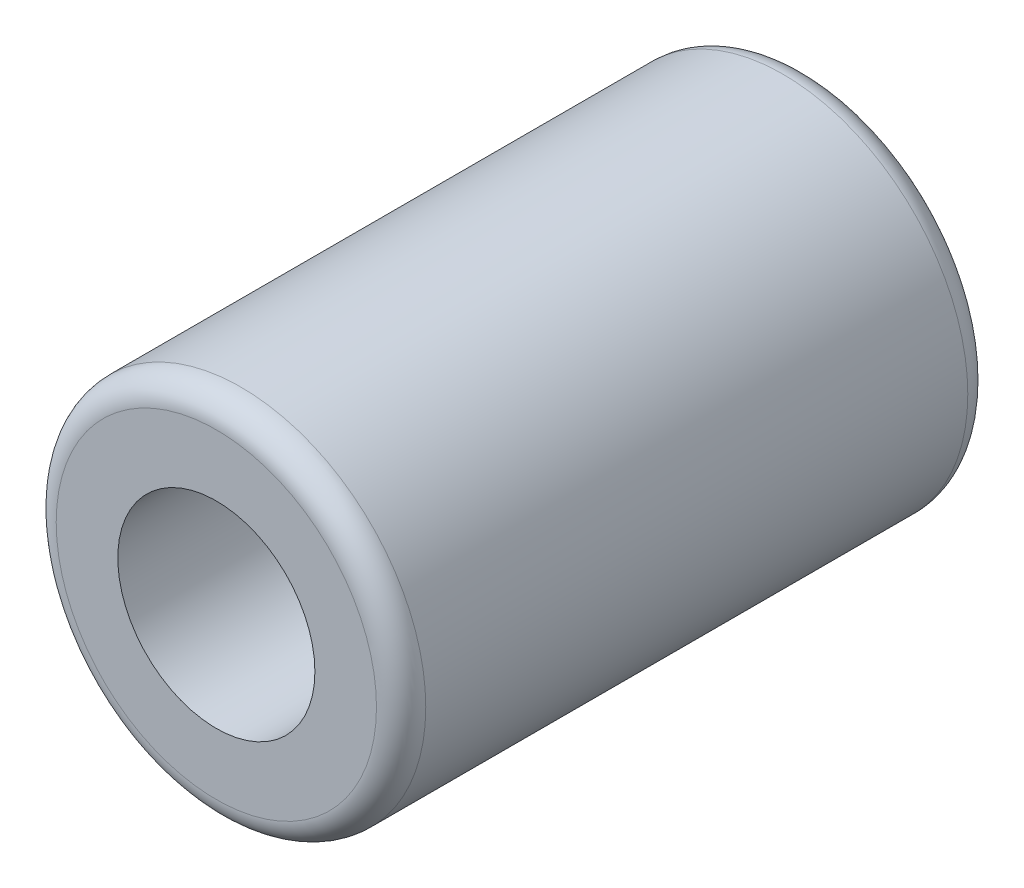
from build123d import *

# Parameters (mm, degrees)
SKETCH1_R           = 7.5
SKETCH1_R_2         = 4
BOSS_EXTRUDE1_DEPTH = 24
FILLET2_R           = 1


with BuildPart() as part:
    # Sketch1 → Boss-Extrude1 (new body)
    with BuildSketch(Plane.XY):
        Circle(SKETCH1_R)
        Circle(SKETCH1_R_2, mode=Mode.SUBTRACT)
    extrude(amount=BOSS_EXTRUDE1_DEPTH)

    # Fillet2
    fillet2_edges = [part.edges().sort_by_distance(p)[0] for p in [
        (-7.5, 0, 0),
        (-7.5, 0, 24),
    ]]
    fillet(fillet2_edges, radius=FILLET2_R)


solid = part.part
